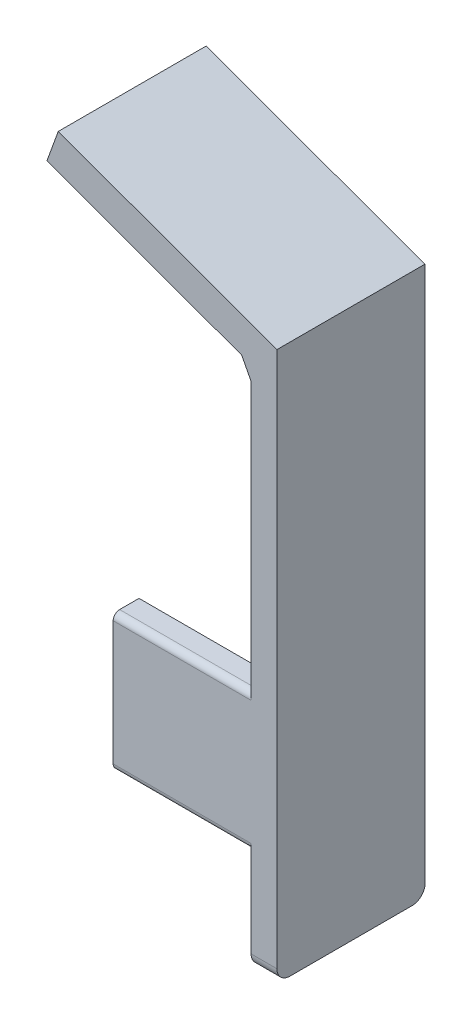
from build123d import *

# Parameters (mm, degrees)
ESQUISSE1_W        = 4
ESQUISSE1_H        = 85
BOSS_EXTRU_1_DEPTH = 22.93
BOSS_EXTRU_5_DEPTH = 22.9
ESQUISSE5_W        = 25.35
ESQUISSE5_H        = 21.181614094
BOSS_EXTRU_6_DEPTH = 4
CONG_1_R           = 2
CONG_5_R           = 1
BOSS_EXTRU_8_DEPTH = 1
BOSS_EXTRU_9_DEPTH = 22.9


with BuildPart() as part:
    # Esquisse1 → Boss.-Extru.1 (new body)
    with BuildSketch(Plane.XY):
        with Locations((-2, -15.95097561)):
            Rectangle(ESQUISSE1_W, ESQUISSE1_H)
    extrude(amount=BOSS_EXTRU_1_DEPTH)

    # Esquisse2 → Boss.-Extru.5 (add)
    with BuildSketch(Plane.XY.offset(22.93)):
        Polygon((-33.850627534, 38.869645224), (0, 26.54902439), (0, 22.54902439), (-4, 22.54902439), (-35.604113867, 34.051981118), align=None)
    extrude(amount=-BOSS_EXTRU_5_DEPTH)

    # Esquisse5 → Boss.-Extru.6 (add)
    with BuildSketch(Plane.XY.offset(22.93)):
        with Locations((-12.675, -32.061782657)):
            Rectangle(ESQUISSE5_W, ESQUISSE5_H)
    extrude(amount=-BOSS_EXTRU_6_DEPTH)

    # Congé1
    cong_1_edges = [part.edges().sort_by_distance(p)[0] for p in [
        (-2, -58.45097561, 22.93),
        (-2, -58.45097561, 0),
    ]]
    fillet(cong_1_edges, radius=CONG_1_R)

    # Congé5
    cong_5_edges = [part.edges().sort_by_distance(p)[0] for p in [
        (-14.675, -21.47097561, 22.93),
        (-14.675, -42.652589704, 22.93),
    ]]
    fillet(cong_5_edges, radius=CONG_5_R)

    # Esquisse10 → Boss.-Extru.8 (add)
    with BuildSketch(Plane.ZY.offset(4)):
        with BuildLine():
            Line((10.166030362, 18.2390183), (11.166631323, 18.2390183))
            add(Edge.make_bspline(
                [(11.166631323, 18.2390183), (11.233404364, 18.238796034), (11.361615999, 18.238369259), (11.545292099, 18.235989598), (11.712187952, 18.22916909), (11.862216294, 18.223299685), (11.995374373, 18.212596912), (12.112070502, 18.202367416), (12.211767213, 18.188976472), (12.272118429, 18.176540153), (12.299443823, 18.170909326)],
                knots=[0, 0, 0, 0, 0.000200323, 0.000384642, 0.000551017, 0.000701421, 0.00083501, 0.000951717, 0.001052854, 0.001136534, 0.001136534, 0.001136534, 0.001136534], degree=3))
            add(Edge.make_bspline(
                [(12.299443823, 18.170909326), (12.336024715, 18.161871089), (12.408406128, 18.143987427), (12.512620508, 18.106187997), (12.611926685, 18.062445676), (12.705912149, 18.011068933), (12.794106136, 17.951676391), (12.877418009, 17.885293359), (12.956225814, 17.812283065), (13.027342428, 17.73080472), (13.094398216, 17.645323991), (13.150953397, 17.552890053), (13.199705511, 17.456230728), (13.238520535, 17.354362988), (13.269774783, 17.248274743), (13.291812268, 17.137005033), (13.30502825, 17.021060783), (13.306373758, 16.941978056), (13.307056003, 16.901878877)],
                knots=[0, 0, 0, 0, 0.000112973, 0.000223535, 0.000332046, 0.000438282, 0.0005444, 0.000650613, 0.000757615, 0.000866163, 0.000974744, 0.001083144, 0.001190647, 0.001299089, 0.001409706, 0.001522064, 0.001638977, 0.001759236, 0.001759236, 0.001759236, 0.001759236], degree=3))
            add(Edge.make_bspline(
                [(13.307056003, 16.901878877), (13.304957434, 16.835257299), (13.300862583, 16.705261345), (13.262683863, 16.516602943), (13.200145978, 16.340618207), (13.113969851, 16.177528725), (13.004227743, 16.030513517), (12.872335184, 15.901384295), (12.718218596, 15.793327277), (12.574748145, 15.718394699), (12.448013574, 15.67040483), (12.34368027, 15.636638603), (12.229870302, 15.610550081), (12.10767411, 15.587178464), (11.976583173, 15.569533186), (11.836911688, 15.55660948), (11.688560043, 15.548532268), (11.586647087, 15.547329403), (11.534219464, 15.546710608)],
                knots=[0, 0, 0, 0, 0.000199681, 0.000389629, 0.000574641, 0.000758347, 0.00094084, 0.00112287, 0.00130963, 0.001503603, 0.001606651, 0.001715936, 0.001832303, 0.001956651, 0.002089094, 0.002228924, 0.002377378, 0.002534658, 0.002534658, 0.002534658, 0.002534658], degree=3))
            Line((11.534219464, 15.546710608), (13.371158567, 13.2390183))
            Line((13.371158567, 13.2390183), (12.816270746, 13.2390183))
            Line((12.816270746, 13.2390183), (10.979331644, 15.546710608))
            Line((10.979331644, 15.546710608), (10.61474831, 15.546710608))
            Line((10.61474831, 15.546710608), (10.61474831, 13.2390183))
            Line((10.61474831, 13.2390183), (10.166030362, 13.2390183))
            Line((10.166030362, 13.2390183), (10.166030362, 18.2390183))
        make_face()
        with BuildLine():
            Line((10.61474831, 17.726197787), (10.61474831, 16.05953112))
            Line((10.61474831, 16.05953112), (11.530213054, 16.052519902))
            add(Edge.make_bspline(
                [(11.530213054, 16.052519902), (11.572955967, 16.052500993), (11.655803905, 16.052464341), (11.775661998, 16.058169736), (11.887262158, 16.06466019), (11.990177518, 16.074587827), (12.084454054, 16.087382215), (12.170044644, 16.103386478), (12.247089004, 16.122032282), (12.336944059, 16.150891747), (12.437281961, 16.196614631), (12.546326904, 16.263136772), (12.639187386, 16.346806942), (12.717641475, 16.442483308), (12.78068352, 16.547677949), (12.825129312, 16.661129905), (12.853332801, 16.779975045), (12.856659294, 16.861658056), (12.858338054, 16.902880479)],
                knots=[0, 0, 0, 0, 0.000128209, 0.000248506, 0.000359904, 0.000463555, 0.000558601, 0.000645233, 0.000724669, 0.000796254, 0.000928055, 0.001054503, 0.00117794, 0.001301056, 0.001424562, 0.001544156, 0.0016654, 0.001788926, 0.001788926, 0.001788926, 0.001788926], degree=3))
            add(Edge.make_bspline(
                [(12.858338054, 16.902880479), (12.856620738, 16.94308987), (12.853217645, 17.022770211), (12.82543369, 17.139421512), (12.778448859, 17.249517155), (12.715131376, 17.352609276), (12.637989726, 17.446188899), (12.547535708, 17.52625626), (12.446242572, 17.592326924), (12.351569432, 17.634547468), (12.266949128, 17.660432973), (12.193478185, 17.678648921), (12.110461789, 17.693283876), (12.017496848, 17.705009678), (11.914980232, 17.715088169), (11.802393588, 17.721876425), (11.680483902, 17.725896231), (11.595988286, 17.726094929), (11.55224831, 17.726197787)],
                knots=[0, 0, 0, 0, 0.00012053, 0.000238846, 0.000357345, 0.000478278, 0.000600621, 0.000719816, 0.000839275, 0.000962126, 0.001029286, 0.001104593, 0.001189072, 0.001282, 0.00138565, 0.001498049, 0.00162031, 0.001751524, 0.001751524, 0.001751524, 0.001751524], degree=3))
            Line((11.55224831, 17.726197787), (10.61474831, 17.726197787))
        make_face(mode=Mode.SUBTRACT)
    extrude(amount=BOSS_EXTRU_8_DEPTH)

    # Esquisse11 → Boss.-Extru.9 (add)
    with BuildSketch(Plane.XY.offset(22.93)):
        Polygon((-5.452843765, 23.077816276), (-4, 20.298440223), (-0.659211444, 23.077816276), align=None)
    extrude(amount=-BOSS_EXTRU_9_DEPTH)


solid = part.part
